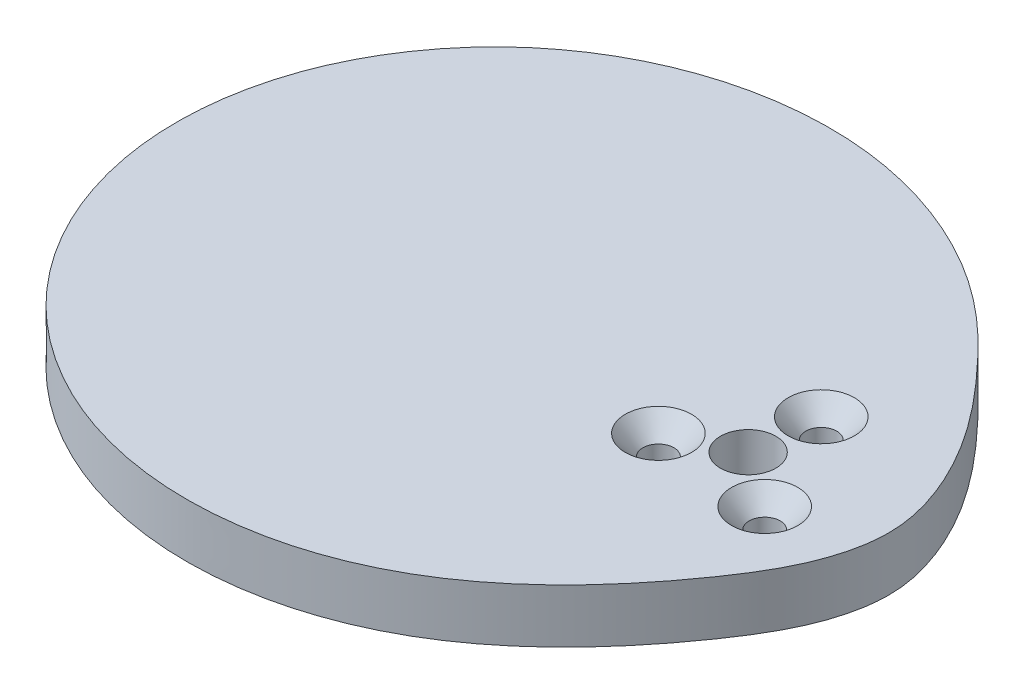
from build123d import *

# Parameters (mm, degrees)
BOSS_EXTRUDE1_DEPTH                               = 3.175
CSK_FOR_6_FLAT_HEAD_SOCKET_CAP_SCREW1_D           = 3.6576
CSK_FOR_6_FLAT_HEAD_SOCKET_CAP_SCREW1_CSINK_D     = 7.7978
CSK_FOR_6_FLAT_HEAD_SOCKET_CAP_SCREW1_CSINK_ANGLE = 82
F_0_257_DIAMETER_HOLE1_D                          = 6.5278


with BuildPart() as part:
    # Sketch4 → Boss-Extrude1 (new body, symmetric)
    with BuildSketch(Plane(origin=(0, 0, 0), x_dir=(1, 0, 0), z_dir=(0, 1, 0))):
        with BuildLine():
            add(Edge.make_bspline(
                [(16.51, 0), (16.512122003, 0.578131647), (16.384658392, 2.985986119), (13.900823918, 11.605758021), (7.810988154, 19.155439574), (0.397856737, 26.753696185), (-7.914709507, 33.453659054), (-20.809856563, 38.186828505), (-34.987409766, 37.85110508), (-46.326695461, 34.282389834), (-57.678006204, 26.336334922), (-64.582391021, 15.700922663), (-66.82228974, 6.758220231), (-67.294278308, 2.143947914), (-67.345909791, -1.429507135), (-66.789369182, -7.815377649), (-63.775863211, -17.415888088), (-55.452256085, -28.466700541), (-43.340466422, -35.829299708), (-29.536622908, -38.571691931), (-16.891586538, -36.932845951), (-5.017956328, -31.482256467), (3.946482544, -23.64766657), (10.468427119, -15.339754563), (15.082180852, -7.959390649), (16.499996307, -2.725468654), (16.51, 0)],
                knots=[0, 0, 0, 0, 0.007033379, 0.029286372, 0.107768427, 0.121103965, 0.158717658, 0.23702597, 0.281652422, 0.329525955, 0.379560175, 0.447772761, 0.478100162, 0.491134389, 0.504172012, 0.521547706, 0.569036322, 0.624460034, 0.686374732, 0.737017154, 0.793225001, 0.838519217, 0.894255247, 0.936255108, 0.966842753, 1, 1, 1, 1], degree=3))
        make_face()
    extrude(amount=BOSS_EXTRUDE1_DEPTH, both=True)

    # CSK for #6 Flat Head Socket Cap Screw1 (through all)
    with Locations(Plane(origin=(0, 3.175, 0), x_dir=(1, 0, 0), z_dir=(0, 1, 0))):
        with Locations((0.692905586, 7.919947089), (6.512422583, -4.560047384), (-7.205328168, -3.359899704)):
            CounterSinkHole(CSK_FOR_6_FLAT_HEAD_SOCKET_CAP_SCREW1_D / 2, CSK_FOR_6_FLAT_HEAD_SOCKET_CAP_SCREW1_CSINK_D / 2, counter_sink_angle=CSK_FOR_6_FLAT_HEAD_SOCKET_CAP_SCREW1_CSINK_ANGLE)

    # F (0.257) Diameter Hole1 (through all)
    with Locations(Plane(origin=(0, 3.175, 0), x_dir=(1, 0, 0), z_dir=(0, 1, 0))):
        with Locations((0, 0)):
            Hole(F_0_257_DIAMETER_HOLE1_D / 2)


solid = part.part
